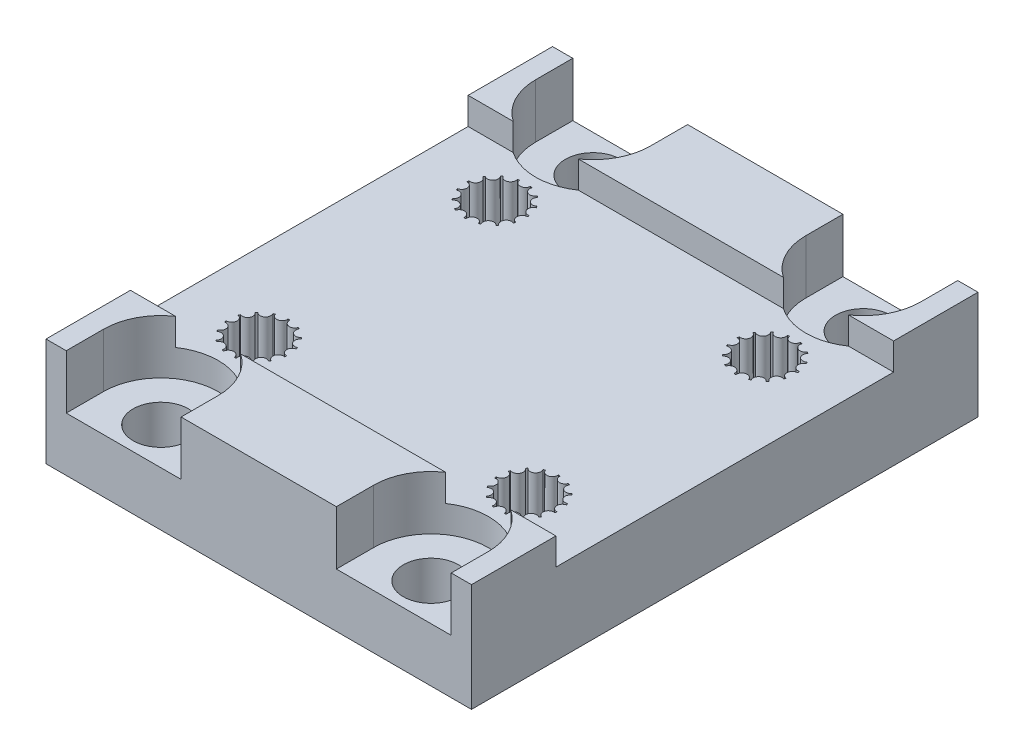
from build123d import *

# Parameters (mm, degrees)
SKETCH1_W                                = 40
SKETCH1_H                                = 37.5
SKETCH1_W_2                              = 20
SKETCH1_H_2                              = 17.5
BOSS_EXTRUDE1_DEPTH                      = 8
CUT_EXTRUDE1_DEPTH                       = 10
MIRROR1_AT_THE_SECOND_PLANE_COPY_1_DEPTH = 10
CUT_EXTRUDE2_DEPTH                       = 14
MIRROR2_AT_THE_SECOND_PLANE_COPY_1_DEPTH = 14
CUT_EXTRUDE3_DEPTH                       = 4
MIRROR3_AT_THE_SECOND_PLANE_COPY_1_DEPTH = 4
SKETCH5_W                                = 60
SKETCH5_H                                = 25
CUT_EXTRUDE4_DEPTH                       = 2
SKETCH8_W                                = 4.25
SKETCH8_H                                = 37.5
CUT_EXTRUDE5_DEPTH                       = 18


with BuildPart() as part:
    # Sketch1 → Boss-Extrude1 (new body)
    with BuildSketch(Plane(origin=(0, 0, 0), x_dir=(1, 0, 0), z_dir=(0, 1, 0))):
        Rectangle(SKETCH1_W, SKETCH1_H)
        Rectangle(SKETCH1_W_2, SKETCH1_H_2, mode=Mode.SUBTRACT)
        Rectangle(SKETCH1_W_2, SKETCH1_H_2)
    extrude(amount=BOSS_EXTRUDE1_DEPTH)

    # Sketch2 → Cut-Extrude1 (cut)
    with BuildSketch(Plane(origin=(0, 8, 0), x_dir=(1, 0, 0), z_dir=(0, 1, 0))):
        with BuildLine():
            ThreePointArc((-7.839332391, 8.122293474), (-8.160134494, 8.556622343), (-7.756040637, 8.914761577))
            ThreePointArc((-7.756040637, 8.914761577), (-7.762325735, 8.985189042), (-7.770820675, 9.055384245))
            ThreePointArc((-7.770820675, 9.055384245), (-8.240545445, 9.32168144), (-8.017055687, 9.813217688))
            ThreePointArc((-8.017055687, 9.813217688), (-8.051442841, 9.875), (-8.087754316, 9.935671305))
            ThreePointArc((-8.087754316, 9.935671305), (-8.625182073, 9.987891622), (-8.620939824, 10.527833803))
            ThreePointArc((-8.620939824, 10.527833803), (-8.677483182, 10.570288237), (-8.735332608, 10.610945025))
            ThreePointArc((-8.735332608, 10.610945025), (-9.24753721, 10.440059097), (-9.463275993, 10.935046302))
            ThreePointArc((-9.463275993, 10.935046302), (-9.532198696, 10.950832102), (-9.601583381, 10.964444444))
            ThreePointArc((-9.601583381, 10.964444444), (-10, 10.6), (-10.398416619, 10.964444444))
            ThreePointArc((-10.398416619, 10.964444444), (-10.467801304, 10.950832102), (-10.536724007, 10.935046302))
            ThreePointArc((-10.536724007, 10.935046302), (-10.520585922, 10.871153089), (-10.515157447, 10.80547728))
            ThreePointArc((-10.515157447, 10.80547728), (-10.814668587, 10.418305497), (-11.264667392, 10.610945025))
            ThreePointArc((-11.264667392, 10.610945025), (-11.322516818, 10.570288237), (-11.379060176, 10.527833803))
            ThreePointArc((-11.379060176, 10.527833803), (-11.299781436, 10.401820533), (-11.272075857, 10.255543864))
            ThreePointArc((-11.272075857, 10.255543864), (-11.49328538, 9.897725523), (-11.912245684, 9.935671305))
            ThreePointArc((-11.912245684, 9.935671305), (-11.948557159, 9.875), (-11.982944313, 9.813217688))
            ThreePointArc((-11.982944313, 9.813217688), (-11.806130896, 9.665772772), (-11.739877162, 9.445288237))
            ThreePointArc((-11.739877162, 9.445288237), (-11.890599069, 9.132461716), (-12.229179325, 9.055384245))
            ThreePointArc((-12.229179325, 9.055384245), (-12.237674265, 8.985189042), (-12.243959363, 8.914761577))
            ThreePointArc((-12.243959363, 8.914761577), (-11.957062468, 8.799867127), (-11.837674265, 8.514810958))
            ThreePointArc((-11.837674265, 8.514810958), (-11.928803206, 8.260648276), (-12.160667609, 8.122293474))
            ThreePointArc((-12.160667609, 8.122293474), (-12.139877162, 8.054711763), (-12.116973454, 7.987816691))
            ThreePointArc((-12.116973454, 7.987816691), (-11.733343913, 7.962169481), (-11.548557159, 7.625))
            ThreePointArc((-11.548557159, 7.625), (-11.59359228, 7.440609287), (-11.718556835, 7.297738864))
            ThreePointArc((-11.718556835, 7.297738864), (-11.672075857, 7.244456136), (-11.623943602, 7.192660224))
            ThreePointArc((-11.623943602, 7.192660224), (-11.182107975, 7.304258631), (-10.922516818, 6.929711763))
            ThreePointArc((-10.922516818, 6.929711763), (-10.936971789, 6.823151777), (-10.979291971, 6.724293398))
            ThreePointArc((-10.979291971, 6.724293398), (-10.915157447, 6.69452272), (-10.850119149, 6.666781953))
            ThreePointArc((-10.850119149, 6.666781953), (-10.408333405, 6.944722659), (-10.067801304, 6.549167898))
            ThreePointArc((-10.067801304, 6.549167898), (-10.068526292, 6.525095823), (-10.070698628, 6.501111007))
            ThreePointArc((-10.070698628, 6.501111007), (-10, 6.5), (-9.929301372, 6.501111007))
            ThreePointArc((-9.929301372, 6.501111007), (-9.615363372, 6.940426939), (-9.149880851, 6.666781953))
            ThreePointArc((-9.149880851, 6.666781953), (-9.084842553, 6.69452272), (-9.020708029, 6.724293398))
            ThreePointArc((-9.020708029, 6.724293398), (-8.912597283, 7.25331856), (-8.376056398, 7.192660224))
            ThreePointArc((-8.376056398, 7.192660224), (-8.327924143, 7.244456136), (-8.281443165, 7.297738864))
            ThreePointArc((-8.281443165, 7.297738864), (-8.397853003, 7.825), (-7.883026546, 7.987816691))
            ThreePointArc((-7.883026546, 7.987816691), (-7.860122838, 8.054711763), (-7.839332391, 8.122293474))
        make_face()
    cut_extrude1 = extrude(amount=-CUT_EXTRUDE1_DEPTH, mode=Mode.SUBTRACT)

    # Mirror1: Cut-Extrude1 across plane
    add(cut_extrude1.mirror(Plane.XY), mode=Mode.SUBTRACT)

    # Mirror1 at the second plane: Cut-Extrude1 across plane
    add(cut_extrude1.mirror(Plane.ZY), mode=Mode.SUBTRACT)

    # Mirror1 at the second plane copy 1 sketc → Mirror1 at the second plane copy 1 (cut)
    with BuildSketch(Plane(origin=(0, 8, 0), x_dir=(-1, 0, 0), z_dir=(0, 1, 0))):
        with BuildLine():
            ThreePointArc((-7.839332391, 8.122293474), (-8.160134494, 8.556622343), (-7.756040637, 8.914761577))
            ThreePointArc((-7.756040637, 8.914761577), (-7.762325735, 8.985189042), (-7.770820675, 9.055384245))
            ThreePointArc((-7.770820675, 9.055384245), (-8.240545445, 9.32168144), (-8.017055687, 9.813217688))
            ThreePointArc((-8.017055687, 9.813217688), (-8.051442841, 9.875), (-8.087754316, 9.935671305))
            ThreePointArc((-8.087754316, 9.935671305), (-8.625182073, 9.987891622), (-8.620939824, 10.527833803))
            ThreePointArc((-8.620939824, 10.527833803), (-8.677483182, 10.570288237), (-8.735332608, 10.610945025))
            ThreePointArc((-8.735332608, 10.610945025), (-9.24753721, 10.440059097), (-9.463275993, 10.935046302))
            ThreePointArc((-9.463275993, 10.935046302), (-9.532198696, 10.950832102), (-9.601583381, 10.964444444))
            ThreePointArc((-9.601583381, 10.964444444), (-10, 10.6), (-10.398416619, 10.964444444))
            ThreePointArc((-10.398416619, 10.964444444), (-10.467801304, 10.950832102), (-10.536724007, 10.935046302))
            ThreePointArc((-10.536724007, 10.935046302), (-10.520585922, 10.871153089), (-10.515157447, 10.80547728))
            ThreePointArc((-10.515157447, 10.80547728), (-10.814668587, 10.418305497), (-11.264667392, 10.610945025))
            ThreePointArc((-11.264667392, 10.610945025), (-11.322516818, 10.570288237), (-11.379060176, 10.527833803))
            ThreePointArc((-11.379060176, 10.527833803), (-11.299781436, 10.401820533), (-11.272075857, 10.255543864))
            ThreePointArc((-11.272075857, 10.255543864), (-11.49328538, 9.897725523), (-11.912245684, 9.935671305))
            ThreePointArc((-11.912245684, 9.935671305), (-11.948557159, 9.875), (-11.982944313, 9.813217688))
            ThreePointArc((-11.982944313, 9.813217688), (-11.806130896, 9.665772772), (-11.739877162, 9.445288237))
            ThreePointArc((-11.739877162, 9.445288237), (-11.890599069, 9.132461716), (-12.229179325, 9.055384245))
            ThreePointArc((-12.229179325, 9.055384245), (-12.237674265, 8.985189042), (-12.243959363, 8.914761577))
            ThreePointArc((-12.243959363, 8.914761577), (-11.957062468, 8.799867127), (-11.837674265, 8.514810958))
            ThreePointArc((-11.837674265, 8.514810958), (-11.928803206, 8.260648276), (-12.160667609, 8.122293474))
            ThreePointArc((-12.160667609, 8.122293474), (-12.139877162, 8.054711763), (-12.116973454, 7.987816691))
            ThreePointArc((-12.116973454, 7.987816691), (-11.733343913, 7.962169481), (-11.548557159, 7.625))
            ThreePointArc((-11.548557159, 7.625), (-11.59359228, 7.440609287), (-11.718556835, 7.297738864))
            ThreePointArc((-11.718556835, 7.297738864), (-11.672075857, 7.244456136), (-11.623943602, 7.192660224))
            ThreePointArc((-11.623943602, 7.192660224), (-11.182107975, 7.304258631), (-10.922516818, 6.929711763))
            ThreePointArc((-10.922516818, 6.929711763), (-10.936971789, 6.823151777), (-10.979291971, 6.724293398))
            ThreePointArc((-10.979291971, 6.724293398), (-10.915157447, 6.69452272), (-10.850119149, 6.666781953))
            ThreePointArc((-10.850119149, 6.666781953), (-10.408333405, 6.944722659), (-10.067801304, 6.549167898))
            ThreePointArc((-10.067801304, 6.549167898), (-10.068526292, 6.525095823), (-10.070698628, 6.501111007))
            ThreePointArc((-10.070698628, 6.501111007), (-10, 6.5), (-9.929301372, 6.501111007))
            ThreePointArc((-9.929301372, 6.501111007), (-9.615363372, 6.940426939), (-9.149880851, 6.666781953))
            ThreePointArc((-9.149880851, 6.666781953), (-9.084842553, 6.69452272), (-9.020708029, 6.724293398))
            ThreePointArc((-9.020708029, 6.724293398), (-8.912597283, 7.25331856), (-8.376056398, 7.192660224))
            ThreePointArc((-8.376056398, 7.192660224), (-8.327924143, 7.244456136), (-8.281443165, 7.297738864))
            ThreePointArc((-8.281443165, 7.297738864), (-8.397853003, 7.825), (-7.883026546, 7.987816691))
            ThreePointArc((-7.883026546, 7.987816691), (-7.860122838, 8.054711763), (-7.839332391, 8.122293474))
        make_face()
    extrude(amount=-MIRROR1_AT_THE_SECOND_PLANE_COPY_1_DEPTH, mode=Mode.SUBTRACT)

    # Sketch3 → Cut-Extrude2 (cut)
    with BuildSketch(Plane(origin=(0, 8, 0), x_dir=(1, 0, 0), z_dir=(0, 1, 0))):
        with BuildLine():
            Line((-10, 13.95), (-10, 16))
            Line((-10, 16), (-7.95, 16))
            ThreePointArc((-7.95, 16), (-11.449568901, 17.449568901), (-10, 13.95))
        make_face()
        with BuildLine():
            Line((-7.95, 16), (-10, 16))
            Line((-10, 16), (-10, 13.95))
            ThreePointArc((-10, 13.95), (-8.550431099, 14.550431099), (-7.95, 16))
        make_face()
    cut_extrude2 = extrude(amount=-CUT_EXTRUDE2_DEPTH, mode=Mode.SUBTRACT)

    # Mirror2: Cut-Extrude2 across plane
    add(cut_extrude2.mirror(Plane.XY), mode=Mode.SUBTRACT)

    # Mirror2 at the second plane: Cut-Extrude2 across plane
    add(cut_extrude2.mirror(Plane.ZY), mode=Mode.SUBTRACT)

    # Mirror2 at the second plane copy 1 sketc → Mirror2 at the second plane copy 1 (cut)
    with BuildSketch(Plane(origin=(0, 8, 0), x_dir=(-1, 0, 0), z_dir=(0, 1, 0))):
        with BuildLine():
            Line((-10, 13.95), (-10, 16))
            Line((-10, 16), (-7.95, 16))
            ThreePointArc((-7.95, 16), (-11.449568901, 17.449568901), (-10, 13.95))
        make_face()
        with BuildLine():
            Line((-7.95, 16), (-10, 16))
            Line((-10, 16), (-10, 13.95))
            ThreePointArc((-10, 13.95), (-8.550431099, 14.550431099), (-7.95, 16))
        make_face()
    extrude(amount=-MIRROR2_AT_THE_SECOND_PLANE_COPY_1_DEPTH, mode=Mode.SUBTRACT)

    # Sketch4 → Cut-Extrude3 (cut)
    with BuildSketch(Plane(origin=(0, 8, 0), x_dir=(1, 0, 0), z_dir=(0, 1, 0))):
        with BuildLine():
            Line((-14.25, 16), (-14.25, 18.75))
            Line((-14.25, 18.75), (-5.75, 18.75))
            Line((-5.75, 18.75), (-5.75, 16))
            ThreePointArc((-5.75, 16), (-10, 11.75), (-14.25, 16))
        make_face()
    cut_extrude3 = extrude(amount=-CUT_EXTRUDE3_DEPTH, mode=Mode.SUBTRACT)

    # Mirror3: Cut-Extrude3 across plane
    add(cut_extrude3.mirror(Plane.XY), mode=Mode.SUBTRACT)

    # Mirror3 at the second plane: Cut-Extrude3 across plane
    add(cut_extrude3.mirror(Plane.ZY), mode=Mode.SUBTRACT)

    # Mirror3 at the second plane copy 1 sketc → Mirror3 at the second plane copy 1 (cut)
    with BuildSketch(Plane(origin=(0, 8, 0), x_dir=(-1, 0, 0), z_dir=(0, 1, 0))):
        with BuildLine():
            Line((-14.25, 16), (-14.25, 18.75))
            Line((-14.25, 18.75), (-5.75, 18.75))
            Line((-5.75, 18.75), (-5.75, 16))
            ThreePointArc((-5.75, 16), (-10, 11.75), (-14.25, 16))
        make_face()
    extrude(amount=-MIRROR3_AT_THE_SECOND_PLANE_COPY_1_DEPTH, mode=Mode.SUBTRACT)

    # Sketch5 → Cut-Extrude4 (cut)
    with BuildSketch(Plane(origin=(0, 8, 0), x_dir=(1, 0, 0), z_dir=(0, 1, 0))):
        Rectangle(SKETCH5_W, SKETCH5_H)
    extrude(amount=-CUT_EXTRUDE4_DEPTH, mode=Mode.SUBTRACT)

    # Sketch8 → Cut-Extrude5 (cut, symmetric)
    with BuildSketch(Plane(origin=(0, 6, 0), x_dir=(1, 0, 0), z_dir=(0, 1, 0))):
        with Locations((-17.875, 0)):
            Rectangle(SKETCH8_W, SKETCH8_H)
    cut_extrude5 = extrude(amount=CUT_EXTRUDE5_DEPTH, both=True, mode=Mode.SUBTRACT)

    # Mirror4: Cut-Extrude5 across plane
    add(cut_extrude5.mirror(Plane.ZY), mode=Mode.SUBTRACT)


solid = part.part
